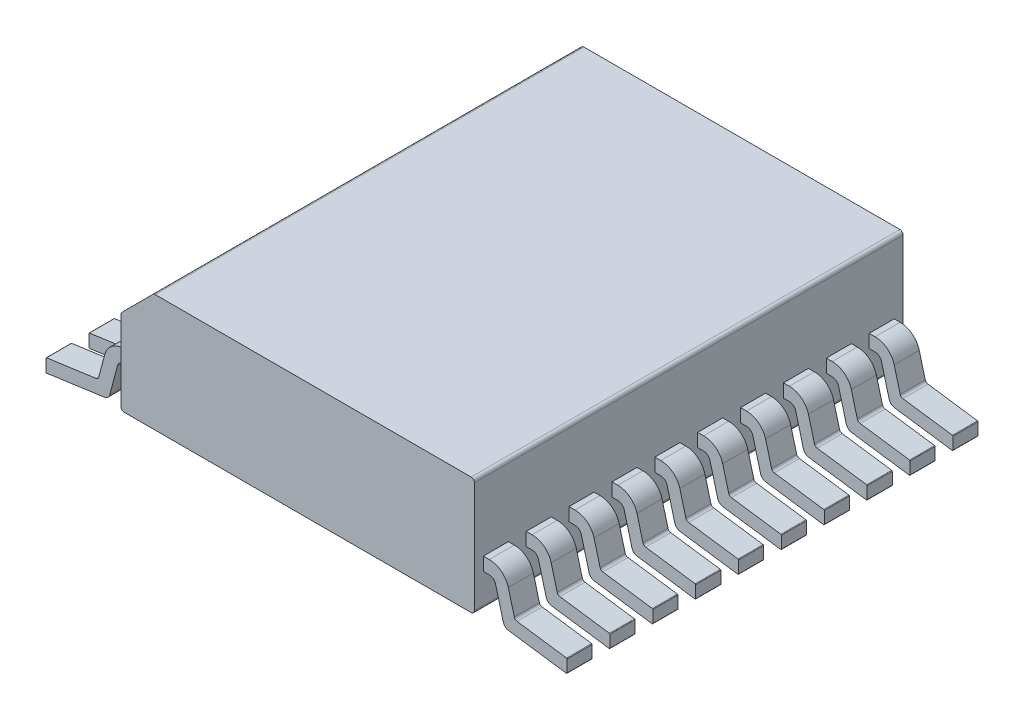
from build123d import *

# Parameters (mm, degrees)
EXTRUDE3_DEPTH       = 0.65
EXTRUDE2_DEPTH       = 0.19
LPATTERN7_COUNT      = 5
LPATTERN7_PITCH      = 0.65
MIRROR1_COPY_1_DEPTH = 0.65
MIRROR1_COPY_2_DEPTH = 0.65
MIRROR1_COPY_3_DEPTH = 0.65
MIRROR1_COPY_4_DEPTH = 0.65
MIRROR1_COPY_5_DEPTH = 0.19
MIRROR1_COPY_6_DEPTH = 0.19
MIRROR1_COPY_7_DEPTH = 0.19
MIRROR1_COPY_8_DEPTH = 0.19


with BuildPart() as part:
    # Sketch3 → Extrude3 (new body)
    with BuildSketch(Plane.XY):
        with BuildLine():
            Line((-2.194644661, 1.765355339), (-2.665355339, 1.294644661))
            ThreePointArc((-2.665355339, 1.294644661), (-2.676193977, 1.278423493), (-2.68, 1.259289322))
            Line((-2.68, 1.259289322), (-2.68, 0.05))
            ThreePointArc((-2.68, 0.05), (-2.665355339, 0.014644661), (-2.63, 0))
            Line((-2.63, 0), (2.63, 0))
            ThreePointArc((2.63, 0), (2.665355339, 0.014644661), (2.68, 0.05))
            Line((2.68, 0.05), (2.68, 1.73))
            ThreePointArc((2.68, 1.73), (2.665355339, 1.765355339), (2.63, 1.78))
            Line((2.63, 1.78), (-2.159289322, 1.78))
            ThreePointArc((-2.159289322, 1.78), (-2.178423493, 1.776193977), (-2.194644661, 1.765355339))
        make_face()
    extrude3 = extrude(amount=-EXTRUDE3_DEPTH)

    # Sketch2 → Extrude2 (add, symmetric)
    with BuildSketch(Plane.XY.offset(-0.325)):
        with BuildLine():
            Line((-2.68, 0.498398997), (-2.769493775, 0.498398997))
            ThreePointArc((-2.769493775, 0.498398997), (-2.830421167, 0.477694979), (-2.866119724, 0.424156054))
            Line((-2.866119724, 0.424156054), (-2.982927831, -0.014042065))
            ThreePointArc((-2.982927831, -0.014042065), (-3.013243396, -0.06313775), (-3.06563647, -0.087311815))
            Line((-3.06563647, -0.087311815), (-3.938608269, -0.21))
            ThreePointArc((-3.938608269, -0.21), (-3.94656059, -0.207644415), (-3.95, -0.200097319))
            Line((-3.95, -0.200097319), (-3.95, -0.018328356))
            ThreePointArc((-3.95, -0.018328356), (-3.947547096, -0.011767766), (-3.941391731, -0.008425676))
            Line((-3.941391731, -0.008425676), (-3.191925795, 0.096904893))
            ThreePointArc((-3.191925795, 0.096904893), (-3.165729258, 0.108991925), (-3.150571476, 0.133539767))
            Line((-3.150571476, 0.133539767), (-3.059371621, 0.47567017))
            ThreePointArc((-3.059371621, 0.47567017), (-2.952275951, 0.636286945), (-2.769493775, 0.698398997))
            Line((-2.769493775, 0.698398997), (-2.68, 0.698398997))
            Line((-2.68, 0.698398997), (-2.68, 0.498398997))
        make_face()
        with BuildLine():
            Line((3.95, -0.200097319), (3.95, -0.018328356))
            ThreePointArc((3.95, -0.018328356), (3.947547096, -0.011767766), (3.941391731, -0.008425676))
            Line((3.941391731, -0.008425676), (3.191925795, 0.096904893))
            ThreePointArc((3.191925795, 0.096904893), (3.165729258, 0.108991925), (3.150571476, 0.133539767))
            Line((3.150571476, 0.133539767), (3.059371621, 0.47567017))
            ThreePointArc((3.059371621, 0.47567017), (2.952275951, 0.636286945), (2.769493775, 0.698398997))
            Line((2.769493775, 0.698398997), (2.68, 0.698398997))
            Line((2.68, 0.698398997), (2.68, 0.498398997))
            Line((2.68, 0.498398997), (2.769493775, 0.498398997))
            ThreePointArc((2.769493775, 0.498398997), (2.830421167, 0.477694979), (2.866119724, 0.424156054))
            Line((2.866119724, 0.424156054), (2.982927831, -0.014042065))
            ThreePointArc((2.982927831, -0.014042065), (3.013243396, -0.06313775), (3.06563647, -0.087311815))
            Line((3.06563647, -0.087311815), (3.938608269, -0.21))
            ThreePointArc((3.938608269, -0.21), (3.94656059, -0.207644415), (3.95, -0.200097319))
        make_face()
    extrude2 = extrude(amount=EXTRUDE2_DEPTH, both=True)

    # LPattern7: Extrude3, Extrude2 ×5
    with Locations(*[(0, 0, -i * LPATTERN7_PITCH) for i in range(1, LPATTERN7_COUNT)]):
        add(extrude3)
        add(extrude2)

    # Mirror1: Extrude3, Extrude2 across plane
    add(extrude3.mirror(Plane.XY))
    add(extrude2.mirror(Plane.XY))

    # Mirror1 copy 1 sketch → Mirror1 copy 1 (add)
    with BuildSketch(Plane(origin=(0, 0, 0.65), x_dir=(1, 0, 0), z_dir=(0, 0, -1))):
        with BuildLine():
            Line((-2.194644661, -1.765355339), (-2.665355339, -1.294644661))
            ThreePointArc((-2.665355339, -1.294644661), (-2.676193977, -1.278423493), (-2.68, -1.259289322))
            Line((-2.68, -1.259289322), (-2.68, -0.05))
            ThreePointArc((-2.68, -0.05), (-2.665355339, -0.014644661), (-2.63, 0))
            Line((-2.63, 0), (2.63, 0))
            ThreePointArc((2.63, 0), (2.665355339, -0.014644661), (2.68, -0.05))
            Line((2.68, -0.05), (2.68, -1.73))
            ThreePointArc((2.68, -1.73), (2.665355339, -1.765355339), (2.63, -1.78))
            Line((2.63, -1.78), (-2.159289322, -1.78))
            ThreePointArc((-2.159289322, -1.78), (-2.178423493, -1.776193977), (-2.194644661, -1.765355339))
        make_face()
    extrude(amount=-MIRROR1_COPY_1_DEPTH)

    # Mirror1 copy 2 sketch → Mirror1 copy 2 (add)
    with BuildSketch(Plane(origin=(0, 0, 1.3), x_dir=(1, 0, 0), z_dir=(0, 0, -1))):
        with BuildLine():
            Line((-2.194644661, -1.765355339), (-2.665355339, -1.294644661))
            ThreePointArc((-2.665355339, -1.294644661), (-2.676193977, -1.278423493), (-2.68, -1.259289322))
            Line((-2.68, -1.259289322), (-2.68, -0.05))
            ThreePointArc((-2.68, -0.05), (-2.665355339, -0.014644661), (-2.63, 0))
            Line((-2.63, 0), (2.63, 0))
            ThreePointArc((2.63, 0), (2.665355339, -0.014644661), (2.68, -0.05))
            Line((2.68, -0.05), (2.68, -1.73))
            ThreePointArc((2.68, -1.73), (2.665355339, -1.765355339), (2.63, -1.78))
            Line((2.63, -1.78), (-2.159289322, -1.78))
            ThreePointArc((-2.159289322, -1.78), (-2.178423493, -1.776193977), (-2.194644661, -1.765355339))
        make_face()
    extrude(amount=-MIRROR1_COPY_2_DEPTH)

    # Mirror1 copy 3 sketch → Mirror1 copy 3 (add)
    with BuildSketch(Plane(origin=(0, 0, 1.95), x_dir=(1, 0, 0), z_dir=(0, 0, -1))):
        with BuildLine():
            Line((-2.194644661, -1.765355339), (-2.665355339, -1.294644661))
            ThreePointArc((-2.665355339, -1.294644661), (-2.676193977, -1.278423493), (-2.68, -1.259289322))
            Line((-2.68, -1.259289322), (-2.68, -0.05))
            ThreePointArc((-2.68, -0.05), (-2.665355339, -0.014644661), (-2.63, 0))
            Line((-2.63, 0), (2.63, 0))
            ThreePointArc((2.63, 0), (2.665355339, -0.014644661), (2.68, -0.05))
            Line((2.68, -0.05), (2.68, -1.73))
            ThreePointArc((2.68, -1.73), (2.665355339, -1.765355339), (2.63, -1.78))
            Line((2.63, -1.78), (-2.159289322, -1.78))
            ThreePointArc((-2.159289322, -1.78), (-2.178423493, -1.776193977), (-2.194644661, -1.765355339))
        make_face()
    extrude(amount=-MIRROR1_COPY_3_DEPTH)

    # Mirror1 copy 4 sketch → Mirror1 copy 4 (add)
    with BuildSketch(Plane(origin=(0, 0, 2.6), x_dir=(1, 0, 0), z_dir=(0, 0, -1))):
        with BuildLine():
            Line((-2.194644661, -1.765355339), (-2.665355339, -1.294644661))
            ThreePointArc((-2.665355339, -1.294644661), (-2.676193977, -1.278423493), (-2.68, -1.259289322))
            Line((-2.68, -1.259289322), (-2.68, -0.05))
            ThreePointArc((-2.68, -0.05), (-2.665355339, -0.014644661), (-2.63, 0))
            Line((-2.63, 0), (2.63, 0))
            ThreePointArc((2.63, 0), (2.665355339, -0.014644661), (2.68, -0.05))
            Line((2.68, -0.05), (2.68, -1.73))
            ThreePointArc((2.68, -1.73), (2.665355339, -1.765355339), (2.63, -1.78))
            Line((2.63, -1.78), (-2.159289322, -1.78))
            ThreePointArc((-2.159289322, -1.78), (-2.178423493, -1.776193977), (-2.194644661, -1.765355339))
        make_face()
    extrude(amount=-MIRROR1_COPY_4_DEPTH)

    # Mirror1 copy 5 sketch → Mirror1 copy 5 (add, symmetric)
    with BuildSketch(Plane(origin=(0, 0, 0.975), x_dir=(1, 0, 0), z_dir=(0, 0, -1))):
        with BuildLine():
            Line((-2.68, -0.498398997), (-2.769493775, -0.498398997))
            ThreePointArc((-2.769493775, -0.498398997), (-2.830421167, -0.477694979), (-2.866119724, -0.424156054))
            Line((-2.866119724, -0.424156054), (-2.982927831, 0.014042065))
            ThreePointArc((-2.982927831, 0.014042065), (-3.013243396, 0.06313775), (-3.06563647, 0.087311815))
            Line((-3.06563647, 0.087311815), (-3.938608269, 0.21))
            ThreePointArc((-3.938608269, 0.21), (-3.94656059, 0.207644415), (-3.95, 0.200097319))
            Line((-3.95, 0.200097319), (-3.95, 0.018328356))
            ThreePointArc((-3.95, 0.018328356), (-3.947547096, 0.011767766), (-3.941391731, 0.008425676))
            Line((-3.941391731, 0.008425676), (-3.191925795, -0.096904893))
            ThreePointArc((-3.191925795, -0.096904893), (-3.165729258, -0.108991925), (-3.150571476, -0.133539767))
            Line((-3.150571476, -0.133539767), (-3.059371621, -0.47567017))
            ThreePointArc((-3.059371621, -0.47567017), (-2.952275951, -0.636286945), (-2.769493775, -0.698398997))
            Line((-2.769493775, -0.698398997), (-2.68, -0.698398997))
            Line((-2.68, -0.698398997), (-2.68, -0.498398997))
        make_face()
        with BuildLine():
            Line((3.95, 0.200097319), (3.95, 0.018328356))
            ThreePointArc((3.95, 0.018328356), (3.947547096, 0.011767766), (3.941391731, 0.008425676))
            Line((3.941391731, 0.008425676), (3.191925795, -0.096904893))
            ThreePointArc((3.191925795, -0.096904893), (3.165729258, -0.108991925), (3.150571476, -0.133539767))
            Line((3.150571476, -0.133539767), (3.059371621, -0.47567017))
            ThreePointArc((3.059371621, -0.47567017), (2.952275951, -0.636286945), (2.769493775, -0.698398997))
            Line((2.769493775, -0.698398997), (2.68, -0.698398997))
            Line((2.68, -0.698398997), (2.68, -0.498398997))
            Line((2.68, -0.498398997), (2.769493775, -0.498398997))
            ThreePointArc((2.769493775, -0.498398997), (2.830421167, -0.477694979), (2.866119724, -0.424156054))
            Line((2.866119724, -0.424156054), (2.982927831, 0.014042065))
            ThreePointArc((2.982927831, 0.014042065), (3.013243396, 0.06313775), (3.06563647, 0.087311815))
            Line((3.06563647, 0.087311815), (3.938608269, 0.21))
            ThreePointArc((3.938608269, 0.21), (3.94656059, 0.207644415), (3.95, 0.200097319))
        make_face()
    extrude(amount=MIRROR1_COPY_5_DEPTH, both=True)

    # Mirror1 copy 6 sketch → Mirror1 copy 6 (add, symmetric)
    with BuildSketch(Plane(origin=(0, 0, 1.625), x_dir=(1, 0, 0), z_dir=(0, 0, -1))):
        with BuildLine():
            Line((-2.68, -0.498398997), (-2.769493775, -0.498398997))
            ThreePointArc((-2.769493775, -0.498398997), (-2.830421167, -0.477694979), (-2.866119724, -0.424156054))
            Line((-2.866119724, -0.424156054), (-2.982927831, 0.014042065))
            ThreePointArc((-2.982927831, 0.014042065), (-3.013243396, 0.06313775), (-3.06563647, 0.087311815))
            Line((-3.06563647, 0.087311815), (-3.938608269, 0.21))
            ThreePointArc((-3.938608269, 0.21), (-3.94656059, 0.207644415), (-3.95, 0.200097319))
            Line((-3.95, 0.200097319), (-3.95, 0.018328356))
            ThreePointArc((-3.95, 0.018328356), (-3.947547096, 0.011767766), (-3.941391731, 0.008425676))
            Line((-3.941391731, 0.008425676), (-3.191925795, -0.096904893))
            ThreePointArc((-3.191925795, -0.096904893), (-3.165729258, -0.108991925), (-3.150571476, -0.133539767))
            Line((-3.150571476, -0.133539767), (-3.059371621, -0.47567017))
            ThreePointArc((-3.059371621, -0.47567017), (-2.952275951, -0.636286945), (-2.769493775, -0.698398997))
            Line((-2.769493775, -0.698398997), (-2.68, -0.698398997))
            Line((-2.68, -0.698398997), (-2.68, -0.498398997))
        make_face()
        with BuildLine():
            Line((3.95, 0.200097319), (3.95, 0.018328356))
            ThreePointArc((3.95, 0.018328356), (3.947547096, 0.011767766), (3.941391731, 0.008425676))
            Line((3.941391731, 0.008425676), (3.191925795, -0.096904893))
            ThreePointArc((3.191925795, -0.096904893), (3.165729258, -0.108991925), (3.150571476, -0.133539767))
            Line((3.150571476, -0.133539767), (3.059371621, -0.47567017))
            ThreePointArc((3.059371621, -0.47567017), (2.952275951, -0.636286945), (2.769493775, -0.698398997))
            Line((2.769493775, -0.698398997), (2.68, -0.698398997))
            Line((2.68, -0.698398997), (2.68, -0.498398997))
            Line((2.68, -0.498398997), (2.769493775, -0.498398997))
            ThreePointArc((2.769493775, -0.498398997), (2.830421167, -0.477694979), (2.866119724, -0.424156054))
            Line((2.866119724, -0.424156054), (2.982927831, 0.014042065))
            ThreePointArc((2.982927831, 0.014042065), (3.013243396, 0.06313775), (3.06563647, 0.087311815))
            Line((3.06563647, 0.087311815), (3.938608269, 0.21))
            ThreePointArc((3.938608269, 0.21), (3.94656059, 0.207644415), (3.95, 0.200097319))
        make_face()
    extrude(amount=MIRROR1_COPY_6_DEPTH, both=True)

    # Mirror1 copy 7 sketch → Mirror1 copy 7 (add, symmetric)
    with BuildSketch(Plane(origin=(0, 0, 2.275), x_dir=(1, 0, 0), z_dir=(0, 0, -1))):
        with BuildLine():
            Line((-2.68, -0.498398997), (-2.769493775, -0.498398997))
            ThreePointArc((-2.769493775, -0.498398997), (-2.830421167, -0.477694979), (-2.866119724, -0.424156054))
            Line((-2.866119724, -0.424156054), (-2.982927831, 0.014042065))
            ThreePointArc((-2.982927831, 0.014042065), (-3.013243396, 0.06313775), (-3.06563647, 0.087311815))
            Line((-3.06563647, 0.087311815), (-3.938608269, 0.21))
            ThreePointArc((-3.938608269, 0.21), (-3.94656059, 0.207644415), (-3.95, 0.200097319))
            Line((-3.95, 0.200097319), (-3.95, 0.018328356))
            ThreePointArc((-3.95, 0.018328356), (-3.947547096, 0.011767766), (-3.941391731, 0.008425676))
            Line((-3.941391731, 0.008425676), (-3.191925795, -0.096904893))
            ThreePointArc((-3.191925795, -0.096904893), (-3.165729258, -0.108991925), (-3.150571476, -0.133539767))
            Line((-3.150571476, -0.133539767), (-3.059371621, -0.47567017))
            ThreePointArc((-3.059371621, -0.47567017), (-2.952275951, -0.636286945), (-2.769493775, -0.698398997))
            Line((-2.769493775, -0.698398997), (-2.68, -0.698398997))
            Line((-2.68, -0.698398997), (-2.68, -0.498398997))
        make_face()
        with BuildLine():
            Line((3.95, 0.200097319), (3.95, 0.018328356))
            ThreePointArc((3.95, 0.018328356), (3.947547096, 0.011767766), (3.941391731, 0.008425676))
            Line((3.941391731, 0.008425676), (3.191925795, -0.096904893))
            ThreePointArc((3.191925795, -0.096904893), (3.165729258, -0.108991925), (3.150571476, -0.133539767))
            Line((3.150571476, -0.133539767), (3.059371621, -0.47567017))
            ThreePointArc((3.059371621, -0.47567017), (2.952275951, -0.636286945), (2.769493775, -0.698398997))
            Line((2.769493775, -0.698398997), (2.68, -0.698398997))
            Line((2.68, -0.698398997), (2.68, -0.498398997))
            Line((2.68, -0.498398997), (2.769493775, -0.498398997))
            ThreePointArc((2.769493775, -0.498398997), (2.830421167, -0.477694979), (2.866119724, -0.424156054))
            Line((2.866119724, -0.424156054), (2.982927831, 0.014042065))
            ThreePointArc((2.982927831, 0.014042065), (3.013243396, 0.06313775), (3.06563647, 0.087311815))
            Line((3.06563647, 0.087311815), (3.938608269, 0.21))
            ThreePointArc((3.938608269, 0.21), (3.94656059, 0.207644415), (3.95, 0.200097319))
        make_face()
    extrude(amount=MIRROR1_COPY_7_DEPTH, both=True)

    # Mirror1 copy 8 sketch → Mirror1 copy 8 (add, symmetric)
    with BuildSketch(Plane(origin=(0, 0, 2.925), x_dir=(1, 0, 0), z_dir=(0, 0, -1))):
        with BuildLine():
            Line((-2.68, -0.498398997), (-2.769493775, -0.498398997))
            ThreePointArc((-2.769493775, -0.498398997), (-2.830421167, -0.477694979), (-2.866119724, -0.424156054))
            Line((-2.866119724, -0.424156054), (-2.982927831, 0.014042065))
            ThreePointArc((-2.982927831, 0.014042065), (-3.013243396, 0.06313775), (-3.06563647, 0.087311815))
            Line((-3.06563647, 0.087311815), (-3.938608269, 0.21))
            ThreePointArc((-3.938608269, 0.21), (-3.94656059, 0.207644415), (-3.95, 0.200097319))
            Line((-3.95, 0.200097319), (-3.95, 0.018328356))
            ThreePointArc((-3.95, 0.018328356), (-3.947547096, 0.011767766), (-3.941391731, 0.008425676))
            Line((-3.941391731, 0.008425676), (-3.191925795, -0.096904893))
            ThreePointArc((-3.191925795, -0.096904893), (-3.165729258, -0.108991925), (-3.150571476, -0.133539767))
            Line((-3.150571476, -0.133539767), (-3.059371621, -0.47567017))
            ThreePointArc((-3.059371621, -0.47567017), (-2.952275951, -0.636286945), (-2.769493775, -0.698398997))
            Line((-2.769493775, -0.698398997), (-2.68, -0.698398997))
            Line((-2.68, -0.698398997), (-2.68, -0.498398997))
        make_face()
        with BuildLine():
            Line((3.95, 0.200097319), (3.95, 0.018328356))
            ThreePointArc((3.95, 0.018328356), (3.947547096, 0.011767766), (3.941391731, 0.008425676))
            Line((3.941391731, 0.008425676), (3.191925795, -0.096904893))
            ThreePointArc((3.191925795, -0.096904893), (3.165729258, -0.108991925), (3.150571476, -0.133539767))
            Line((3.150571476, -0.133539767), (3.059371621, -0.47567017))
            ThreePointArc((3.059371621, -0.47567017), (2.952275951, -0.636286945), (2.769493775, -0.698398997))
            Line((2.769493775, -0.698398997), (2.68, -0.698398997))
            Line((2.68, -0.698398997), (2.68, -0.498398997))
            Line((2.68, -0.498398997), (2.769493775, -0.498398997))
            ThreePointArc((2.769493775, -0.498398997), (2.830421167, -0.477694979), (2.866119724, -0.424156054))
            Line((2.866119724, -0.424156054), (2.982927831, 0.014042065))
            ThreePointArc((2.982927831, 0.014042065), (3.013243396, 0.06313775), (3.06563647, 0.087311815))
            Line((3.06563647, 0.087311815), (3.938608269, 0.21))
            ThreePointArc((3.938608269, 0.21), (3.94656059, 0.207644415), (3.95, 0.200097319))
        make_face()
    extrude(amount=MIRROR1_COPY_8_DEPTH, both=True)


solid = part.part
